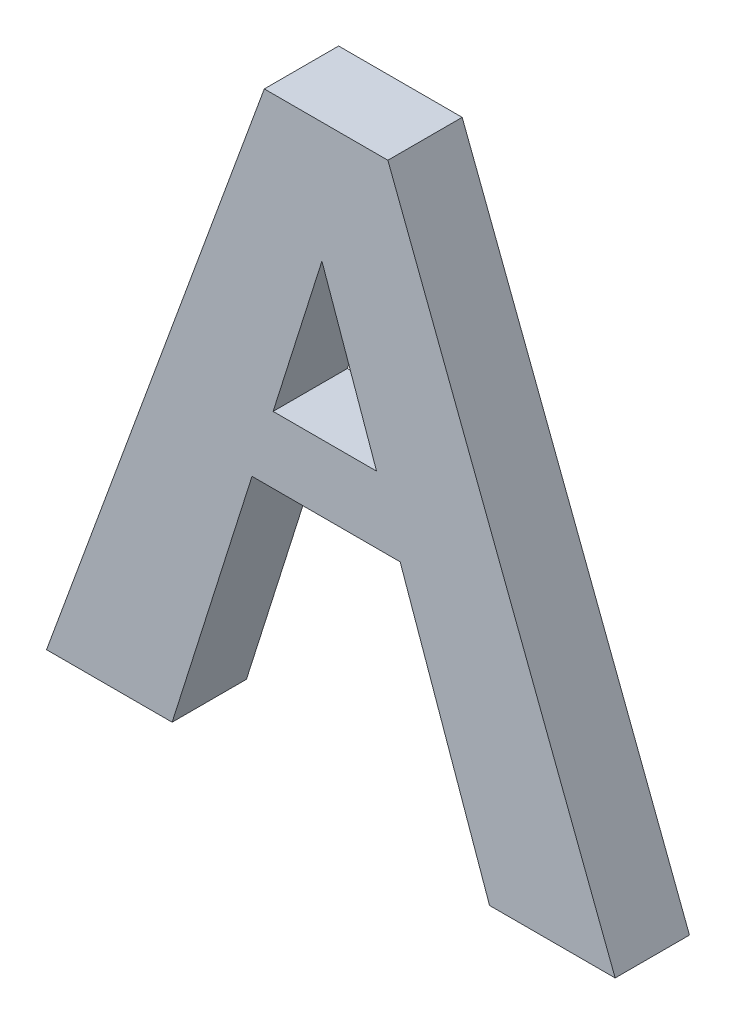
from build123d import *

# Parameters (mm, degrees)
BOSS_EXTRUDE1_DEPTH = 3.175


with BuildPart() as part:
    # Sketch1 → Boss-Extrude1 (new body, symmetric)
    with BuildSketch(Plane.XY):
        Polygon((-5.278441348, 29.190879636), (5.278441348, 29.190879636), (24.698908797, -21.609120364), (13.966676058, -21.609120364), (6.328370689, 0), (-6.328370689, 0), (-13.154027538, -21.609120364), (-23.886260277, -21.609120364), align=None)
        Polygon((-0.355555483, 18.909137327), (4.312269234, 5.703644579), (-4.526764699, 5.703644579), align=None, mode=Mode.SUBTRACT)
    extrude(amount=BOSS_EXTRUDE1_DEPTH, both=True)


solid = part.part
